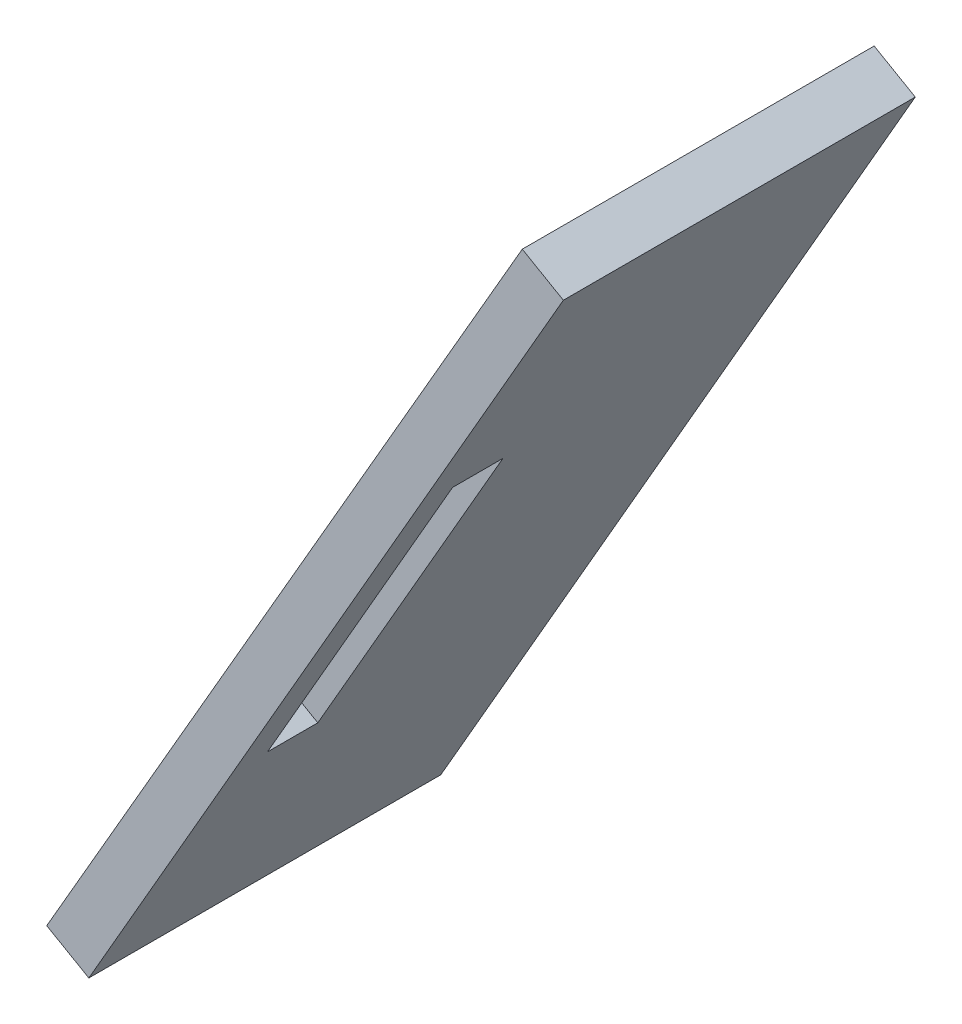
from build123d import *

# Parameters (mm, degrees)
SALIENTE_EXTRUIR1_DEPTH = 37
CROQUIS2_W              = 5.3
CROQUIS2_H              = 39.018100287
CORTAR_EXTRUIR1_DEPTH   = 10


with BuildPart() as part:
    # Croquis1 → Saliente-Extruir1 (new body)
    with BuildSketch(Plane.XY):
        Polygon((49.999999971, -86.602540395), (54.427653304, -89.151580069), (104.320933147, -2.487512391), (100, -3.4e-08), align=None)
    extrude(amount=SALIENTE_EXTRUIR1_DEPTH)

    # Croquis2 → Cortar-Extruir1 (cut)
    with BuildSketch(Plane(origin=(79.427501571, -45.727123931, 0), x_dir=(0, 0, -1), z_dir=(0.866640677, -0.498932798, 0))):
        with Locations((-30.774409531, -0.136173332)):
            Rectangle(CROQUIS2_W, CROQUIS2_H)
    extrude(amount=-CORTAR_EXTRUIR1_DEPTH, mode=Mode.SUBTRACT)


solid = part.part
